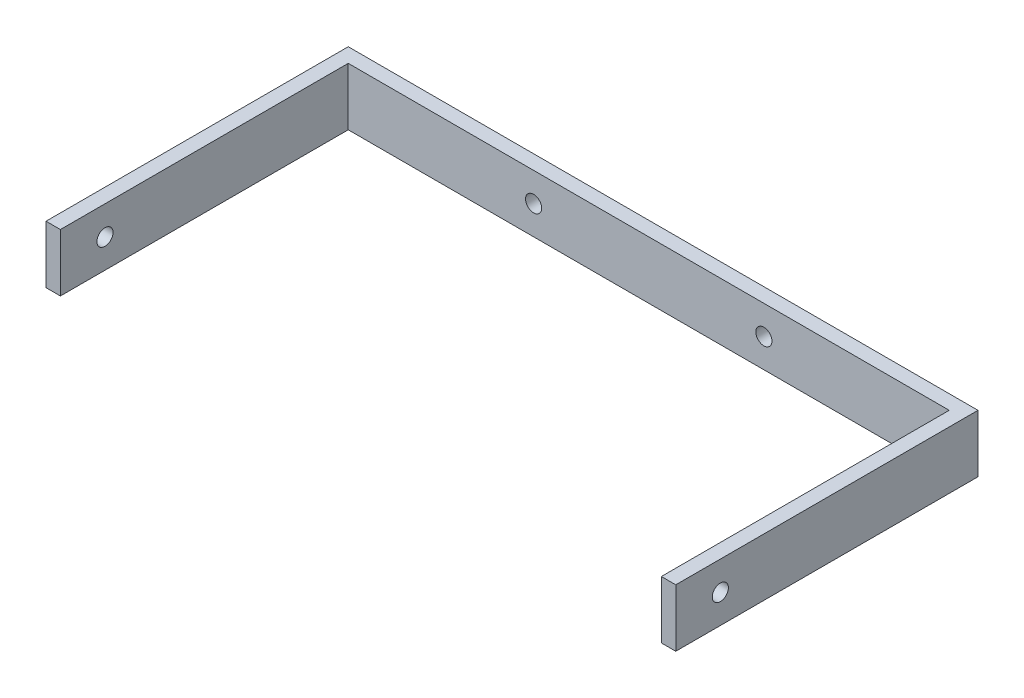
from build123d import *

# Parameters (mm, degrees)
SKETCH1_W           = 138.92560988
SKETCH1_H           = 12.7
SKETCH1_R           = 1.778
BOSS_EXTRUDE1_DEPTH = 3.175
SKETCH2_W           = 3.175
SKETCH2_H           = 12.7
BOSS_EXTRUDE2_DEPTH = 63.5
SKETCH3_R           = 1.778
CUT_EXTRUDE1_DEPTH  = 152.4


with BuildPart() as part:
    # Sketch1 → Boss-Extrude1 (new body)
    with BuildSketch(Plane.XY):
        with Locations((-69.46280494, -6.35)):
            Rectangle(SKETCH1_W, SKETCH1_H)
        with Locations((-94.86280494, -6.35)):
            Circle(SKETCH1_R, mode=Mode.SUBTRACT)
        with Locations((-44.06280494, -6.35)):
            Circle(SKETCH1_R, mode=Mode.SUBTRACT)
    extrude(amount=BOSS_EXTRUDE1_DEPTH)

    # Sketch2 → Boss-Extrude2 (add)
    with BuildSketch(Plane.XY.offset(3.175)):
        with Locations((-137.33810988, -6.35)):
            Rectangle(SKETCH2_W, SKETCH2_H)
        with Locations((-1.5875, -6.35)):
            Rectangle(SKETCH2_W, SKETCH2_H)
    extrude(amount=BOSS_EXTRUDE2_DEPTH)

    # Sketch3 → Cut-Extrude1 (cut)
    with BuildSketch(Plane(origin=(0, 0, 0), x_dir=(0, 0, -1), z_dir=(1, 0, 0))):
        with Locations((-56.840236332, -6.35)):
            Circle(SKETCH3_R)
    extrude(amount=-CUT_EXTRUDE1_DEPTH, mode=Mode.SUBTRACT)


solid = part.part
